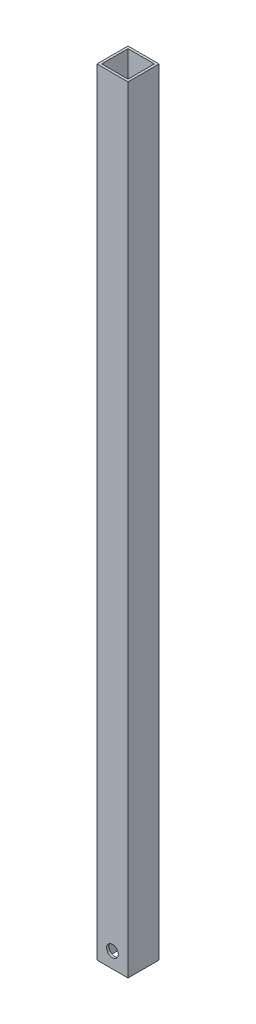
from build123d import *

# Parameters (mm, degrees)
CROQUIS1_W              = 40
CROQUIS1_H              = 40
CROQUIS1_W_2            = 34
CROQUIS1_H_2            = 34
SALIENTE_EXTRUIR1_DEPTH = 1000
CROQUIS2_R              = 7.5
CORTAR_EXTRUIR1_DEPTH   = 41


with BuildPart() as part:
    # Croquis1 → Saliente-Extruir1 (new body)
    with BuildSketch(Plane(origin=(0, 0, 0), x_dir=(1, 0, 0), z_dir=(0, 1, 0))):
        Rectangle(CROQUIS1_W, CROQUIS1_H)
        Rectangle(CROQUIS1_W_2, CROQUIS1_H_2, mode=Mode.SUBTRACT)
    extrude(amount=SALIENTE_EXTRUIR1_DEPTH)

    # Croquis2 → Cortar-Extruir1 (cut, through all)
    with BuildSketch(Plane(origin=(0, 0, -20), x_dir=(-1, 0, 0), z_dir=(0, 0, -1))):
        with Locations((0, 20)):
            Circle(CROQUIS2_R)
    extrude(amount=-CORTAR_EXTRUIR1_DEPTH, mode=Mode.SUBTRACT)


solid = part.part
